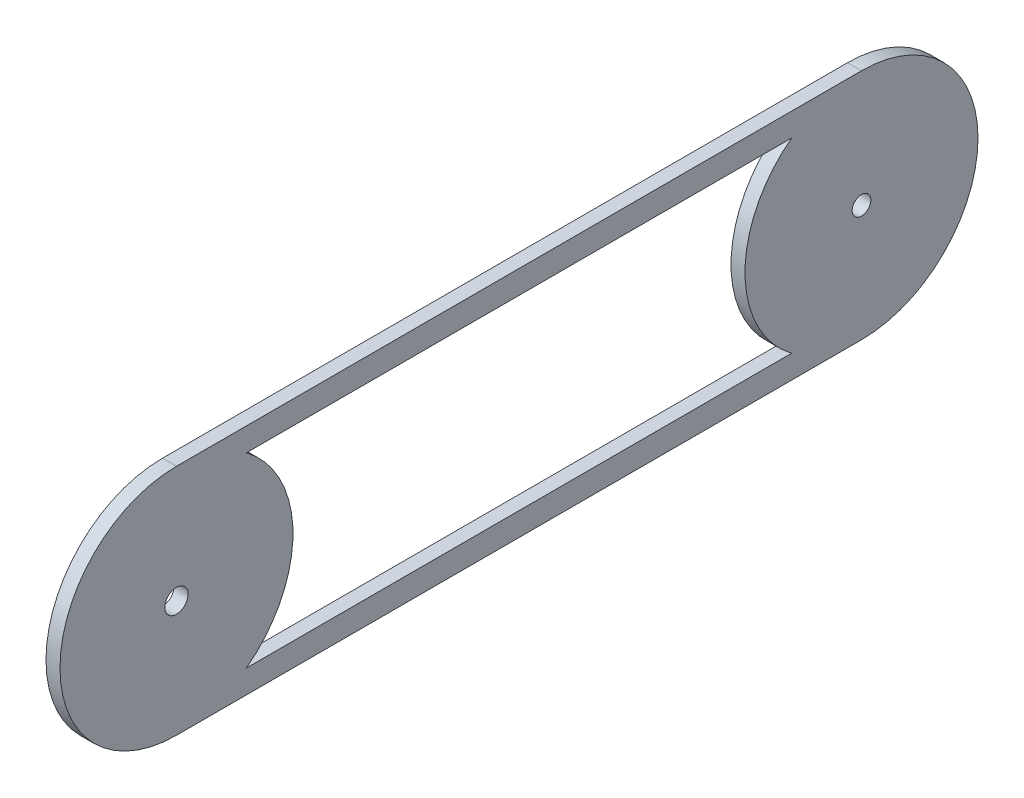
from build123d import *

# Parameters (mm, degrees)
SKETCH1_R           = 2
SKETCH1_R_2         = 2.5
BOSS_EXTRUDE1_DEPTH = 3


with BuildPart() as part:
    # Sketch1 → Boss-Extrude1 (new body)
    with BuildSketch(Plane(origin=(0, 0, 0), x_dir=(0, 0, -1), z_dir=(1, 0, 0))):
        with BuildLine():
            Line((0, 25), (-147, 25))
            ThreePointArc((-147, 25), (-172, 0), (-147, -25))
            Line((-147, -25), (0, -25))
            ThreePointArc((0, -25), (25, 0), (0, 25))
        make_face()
        with BuildLine():
            Line((-132, 20), (-15, 20))
            ThreePointArc((-15, 20), (-25, 0), (-15, -20))
            Line((-15, -20), (-132, -20))
            ThreePointArc((-132, -20), (-122, 0), (-132, 20))
        make_face(mode=Mode.SUBTRACT)
        Circle(SKETCH1_R, mode=Mode.SUBTRACT)
        with Locations((-147, 0)):
            Circle(SKETCH1_R_2, mode=Mode.SUBTRACT)
    extrude(amount=BOSS_EXTRUDE1_DEPTH)


solid = part.part
